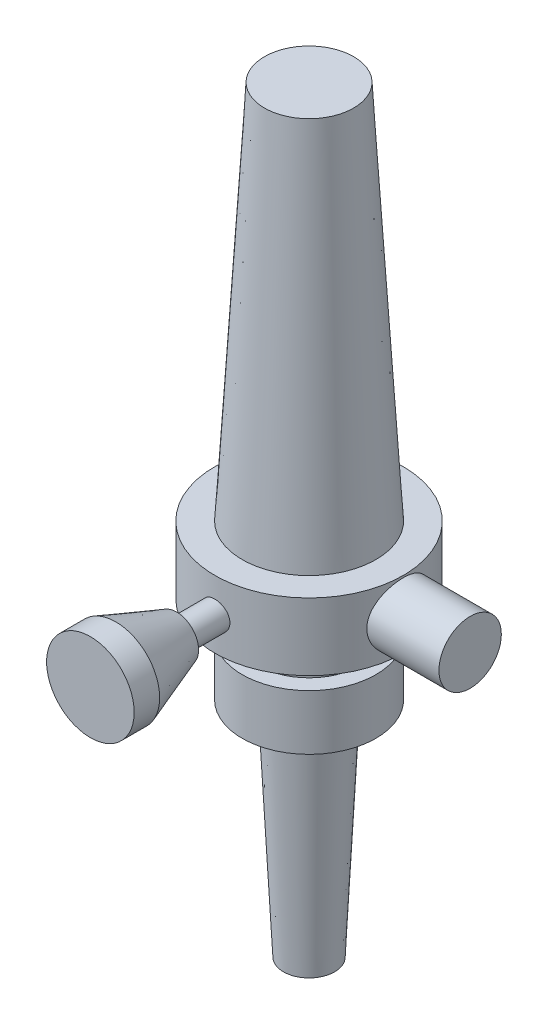
from build123d import *

# Parameters (mm, degrees)
SKETCH_2_R           = 7
EXTRUDE_1_DEPTH      = 15
EXTRUDE_1_DEPTH_BACK = 5


with BuildPart() as part:
    # Эскиз1 → Повернуть2 (revolve)
    with BuildSketch(Plane.XY):
        Polygon((0, 0), (5.740181269, 0), (8.157099698, 50), (15, 50), (15, 62.386706949), (11.480362538, 62.386706949), (11.480362538, 69.637462236), (21.148036254, 69.637462236), (21.148036254, 84.743202417), (15, 84.743202417), (10, 170), (0, 170), align=None)
    revolve(axis=Axis((0, 0, 0), (0, 1, 0)))

    # Эскиз2 → Бобышка-Вытянуть1 (add, two sides)
    with BuildSketch(Plane(origin=(21.148036254, 0, 0), x_dir=(0, 0, -1), z_dir=(1, 0, 0))) as extrude_1_sk:
        with Locations((0, 77.29820462)):
            Circle(SKETCH_2_R)
    extrude(amount=EXTRUDE_1_DEPTH)
    extrude(extrude_1_sk.sketch, amount=-EXTRUDE_1_DEPTH_BACK)

    # Эскиз3 → Повернуть3 (revolve)
    with BuildSketch(Plane(origin=(0, 0, 0), x_dir=(0, 0, -1), z_dir=(1, 0, 0))):
        Polygon((-49.069170568, 77), (-49.069170568, 86.826198905), (-43.352373997, 86.826198905), (-29.695582188, 81.913099452), (-29.695582188, 80.156602905), (-20.167587903, 80.156602905), (-20.167587903, 77), align=None)
    revolve(axis=Axis((0, 77, 70.030757994), (0, 0, -1)))


solid = part.part
